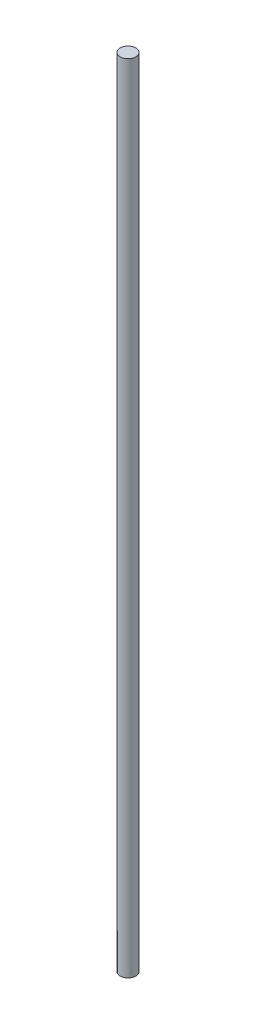
from build123d import *

# Parameters (mm, degrees)
SKETCH1_W = 4
SKETCH1_H = 408


with BuildPart() as part:
    # Sketch1 → Revolve1 (revolve)
    with BuildSketch(Plane.XY):
        with Locations((2, 0)):
            Rectangle(SKETCH1_W, SKETCH1_H)
    revolve(axis=Axis((0, 204, 0), (0, -1, 0)))


solid = part.part
